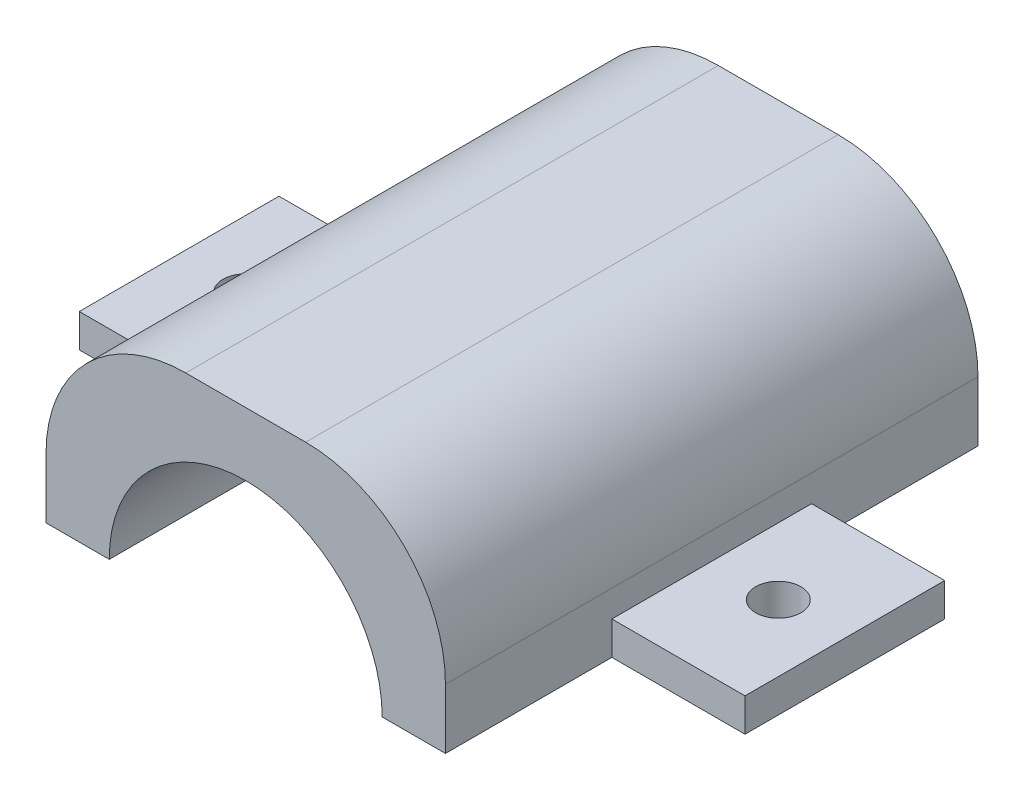
from build123d import *

# Parameters (mm, degrees)
SKETCH1_W                     = 30
SKETCH1_H                     = 40
BOSS_EXTRUDE1_DEPTH           = 15
SKETCH2_R                     = 10.25
CUT_EXTRUDE1_DEPTH            = 41
SKETCH3_W                     = 10
SKETCH3_H                     = 15
BOSS_EXTRUDE2_DEPTH           = 2.5
SKETCH4_W                     = 10
SKETCH4_H                     = 15
BOSS_EXTRUDE3_DEPTH           = 2.5
SKETCH6_W                     = 1.7
SKETCH6_H                     = 2.501
M3_CLEARANCE_HOLE1_AT_2_COUNT = 2
M3_CLEARANCE_HOLE1_AT_2_PITCH = 40
FILLET1_R                     = 10.5


with BuildPart() as part:
    # Sketch1 → Boss-Extrude1 (new body)
    with BuildSketch(Plane(origin=(0, 0, 0), x_dir=(1, 0, 0), z_dir=(0, 1, 0))):
        with Locations((0.340314136, -0.628272251)):
            Rectangle(SKETCH1_W, SKETCH1_H)
    extrude(amount=BOSS_EXTRUDE1_DEPTH)

    # Sketch2 → Cut-Extrude1 (cut, through all)
    with BuildSketch(Plane.XY.offset(20.628272251)):
        with Locations((0.340314136, 0)):
            Circle(SKETCH2_R)
    extrude(amount=-CUT_EXTRUDE1_DEPTH, mode=Mode.SUBTRACT)

    # Sketch4 → Boss-Extrude3 (add)
    with BuildSketch(Plane.XZ):
        with Locations((20.340314136, 0.628272251)):
            Rectangle(SKETCH4_W, SKETCH4_H)
    extrude(amount=-BOSS_EXTRUDE3_DEPTH)

    # Sketch6 → M3 Clearance Hole1 (revolve, cut)
    with BuildSketch(Plane(origin=(20.340314136, 0, 0.628272251), x_dir=(0, 0, -1), z_dir=(1, 0, 0))):
        with Locations((0.85, 1.2505)):
            Rectangle(SKETCH6_W, SKETCH6_H)
    m3_clearance_hole1 = revolve(axis=Axis((20.340314136, -6.35, 0.628272251), (0, 1, 0)), mode=Mode.SUBTRACT)

    # Fillet1
    fillet1_edges = [part.edges().sort_by_distance(p)[0] for p in [
        (15.340314136, 15, 0.628272251),
        (-14.659685864, 15, 0.628272251),
    ]]
    fillet(fillet1_edges, radius=FILLET1_R)


with BuildPart() as body_2:
    # Sketch3 → Boss-Extrude2 (new body)
    with BuildSketch(Plane(origin=(0, 0, 0), x_dir=(-1, 0, 0), z_dir=(0, -1, 0))):
        with Locations((19.659685864, -0.628272251)):
            Rectangle(SKETCH3_W, SKETCH3_H)
    extrude(amount=-BOSS_EXTRUDE2_DEPTH)

    # M3 Clearance Hole1 at 2: M3 Clearance Hole1 ×2
    with Locations(*[(-i * M3_CLEARANCE_HOLE1_AT_2_PITCH, 0, 0) for i in range(1, M3_CLEARANCE_HOLE1_AT_2_COUNT)]):
        add(m3_clearance_hole1, mode=Mode.SUBTRACT)


solid = Compound([part.part, body_2.part])
